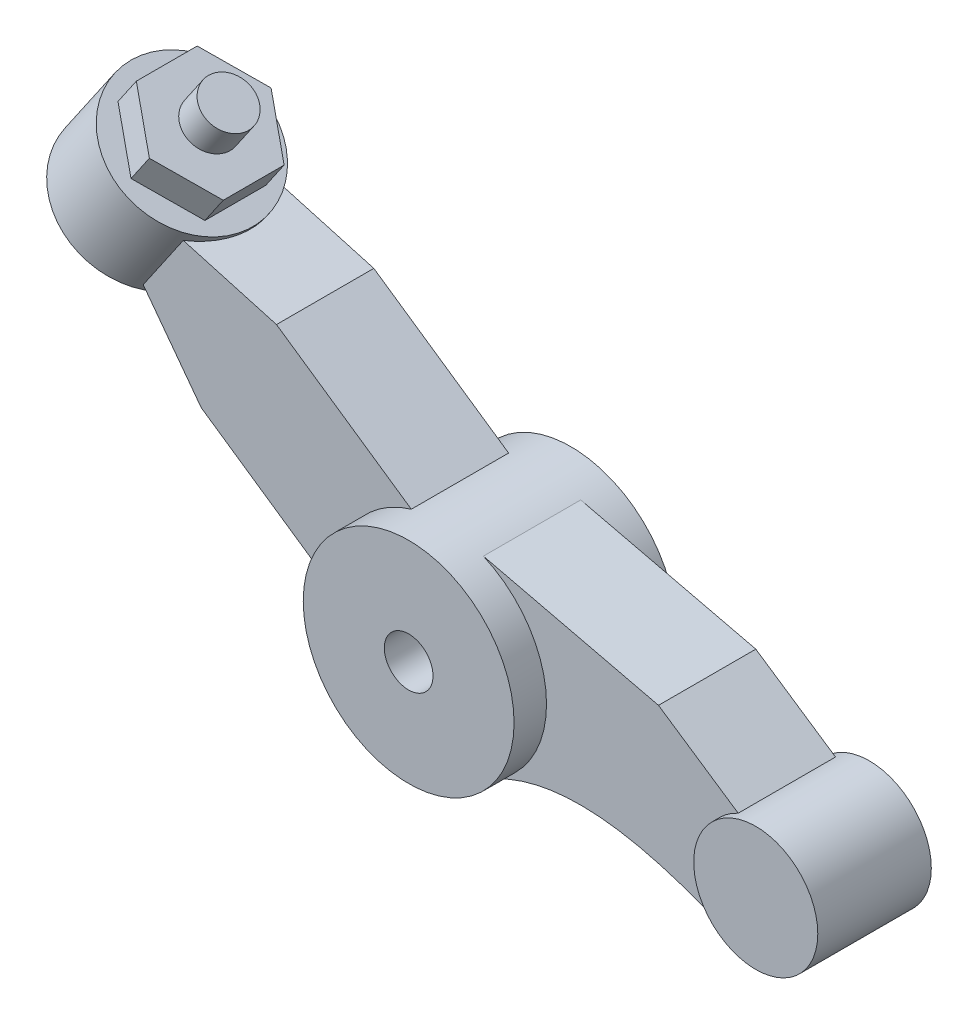
from build123d import *

# Parameters (mm, degrees)
SKETCH1_R           = 0.3
BOSS_EXTRUDE1_DEPTH = 1
BOSS_EXTRUDE2_DEPTH = 0.7
BOSS_EXTRUDE3_DEPTH = 0.6
BOSS_EXTRUDE4_DEPTH = 0.6
BOSS_EXTRUDE5_DEPTH = 0.4
SKETCH5_R           = 0.3
BOSS_EXTRUDE6_DEPTH = 0.4


with BuildPart() as part:
    # Sketch1 → Boss-Extrude1 (new, symmetric)
    with BuildSketch(Plane.XY):
        with BuildLine():
            ThreePointArc((1.3, 0), (1.088137361, 0.711306603), (0.521604487, 1.190768138))
            ThreePointArc((0.521604487, 1.190768138), (0.081992884, 1.297411718), (-0.36754671, 1.24696007))
            ThreePointArc((-0.36754671, 1.24696007), (-1.071749439, 0.735767042), (-1.295745132, -0.105093068))
            ThreePointArc((-1.295745132, -0.105093068), (-0.590185628, -1.158309512), (0.676601677, -1.110049626))
            ThreePointArc((0.676601677, -1.110049626), (1.133486255, -0.636560217), (1.3, 0))
        make_face()
        Circle(SKETCH1_R, mode=Mode.SUBTRACT)
    extrude(amount=BOSS_EXTRUDE1_DEPTH, both=True)



with BuildPart() as body_2:
    # Sketch1_3 → Boss-Extrude2 (new, symmetric)
    with BuildSketch(Plane.XY):
        with BuildLine():
            ThreePointArc((4.745, -0.68), (4.394192677, -0.036828618), (3.663511304, 0.016462422))
            ThreePointArc((3.663511304, 0.016462422), (3.215, -0.68), (3.663511304, -1.376462422))
            ThreePointArc((3.663511304, -1.376462422), (4.394192677, -1.323171382), (4.745, -0.68))
        make_face()
    extrude(amount=BOSS_EXTRUDE2_DEPTH, both=True)


with BuildPart() as part_1:
    add(part.part)

    add(body_2.part)  # Boss-Extrude3 merges body 2
    # Sketch1_4 → Boss-Extrude3 (add, symmetric)
    with BuildSketch(Plane.XY):
        with BuildLine():
            ThreePointArc((3.663511304, -1.376462422), (3.215, -0.68), (3.663511304, 0.016462422))
            Line((3.663511304, 0.016462422), (2.68078674, 0.677070497))
            Line((2.68078674, 0.677070497), (0.521604487, 1.190768138))
            ThreePointArc((0.521604487, 1.190768138), (1.088137361, 0.711306603), (1.3, 0))
            ThreePointArc((1.3, 0), (1.133486255, -0.636560217), (0.676601677, -1.110049626))
            add(Edge.make_bspline(
                [(3.663511304, -1.376462422), (2.756337447, -0.967349054), (1.621818, -0.614489974), (0.676601677, -1.110049626)],
                knots=[0, 0, 0, 0, 1, 1, 1, 1], degree=3))
        make_face()
    extrude(amount=BOSS_EXTRUDE3_DEPTH, both=True)

    # Sketch1_5 → Boss-Extrude4 (add, symmetric)
    with BuildSketch(Plane.XY):
        with BuildLine():
            ThreePointArc((-1.295745132, -0.105093068), (-1.071749439, 0.735767042), (-0.36754671, 1.24696007))
            Line((-0.36754671, 1.24696007), (-2.029761859, 2.388087912))
            Line((-2.029761859, 2.388087912), (-3.468005165, 2.793231136))
            Line((-3.468005165, 2.793231136), (-3.852867925, 2.232623737))
            Line((-3.852867925, 2.232623737), (-2.957960282, 1.036034774))
            Line((-2.957960282, 1.036034774), (-1.295745132, -0.105093068))
        make_face()
    extrude(amount=BOSS_EXTRUDE4_DEPTH, both=True)



with BuildPart() as body_2_2:
    # Sketch2 → Revolve1 (revolve)
    with BuildSketch(Plane.XY):
        with BuildLine():
            Line((-3.852867925, 2.232623737), (-3.445366179, 2.826208042))
            Line((-3.445366179, 2.826208042), (-3.775135237, 3.052597901))
            Line((-3.775135237, 3.052597901), (-4.815155649, 1.537660116))
            ThreePointArc((-4.815155649, 1.537660116), (-4.383926247, 1.56515911), (-4.30804714, 1.990549933))
            Line((-4.30804714, 1.990549933), (-3.852867925, 2.232623737))
        make_face()
    revolve(axis=Axis((-3.775135237, 3.052597901, 0), (-0.565974647839502, -0.8244226452511793, 0)))


with BuildPart() as part_2:
    add(part_1.part)

    add(body_2_2.part)  # Revolve2 merges body 2 2
    # Sketch3 → Revolve2 (revolve)
    with BuildSketch(Plane.XY):
        Polygon((-3.6732598, 3.200993977), (-4.28451242, 2.31061752), (-5.034737027, 2.82565445), (-4.423484407, 3.716030906), align=None)
    revolve(axis=Axis((-3.6732598, 3.200993977, 0), (-0.5659746478395014, -0.8244226452511797, 0)))

    # Sketch4 → Boss-Extrude5 (add)
    with BuildSketch(Plane(origin=(0.316945803, 0.461676681, 0), x_dir=(0.8244226452511795, -0.5659746478395015, 0), z_dir=(0.5659746478395016, 0.8244226452511796, 0))):
        Polygon((-4.84, 0.75055535), (-5.49, 0.375277675), (-5.49, -0.375277675), (-4.84, -0.75055535), (-4.19, -0.375277675), (-4.19, 0.375277675), align=None)
    extrude(amount=BOSS_EXTRUDE5_DEPTH)

    # Sketch5 → Boss-Extrude6 (add)
    with BuildSketch(Plane(origin=(0.543335662, 0.791445739, 0), x_dir=(0.8244226452511795, -0.5659746478395015, 0), z_dir=(0.5659746478395016, 0.8244226452511796, 0))):
        with Locations((-4.84, 0)):
            Circle(SKETCH5_R)
    extrude(amount=BOSS_EXTRUDE6_DEPTH)


solid = part_2.part
